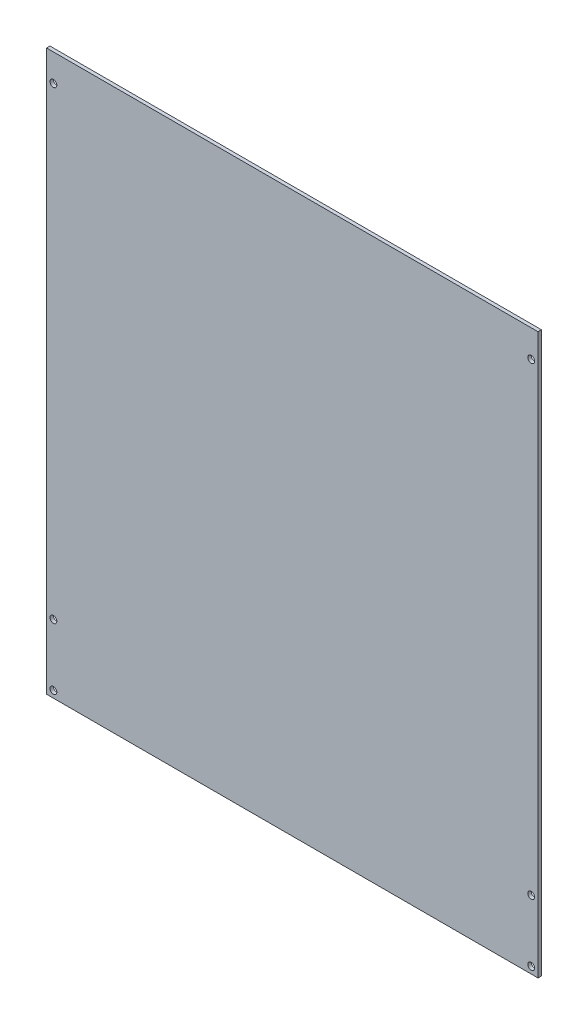
from build123d import *

# Parameters (mm, degrees)
SKETCH1_W           = 457.2
SKETCH1_H           = 520.7
BOSS_EXTRUDE1_DEPTH = 3.175
SKETCH2_R           = 3.175
CUT_EXTRUDE1_DEPTH  = 3.175


with BuildPart() as part:
    # Sketch1 → Boss-Extrude1 (new body)
    with BuildSketch(Plane.XY):
        Rectangle(SKETCH1_W, SKETCH1_H)
    extrude(amount=BOSS_EXTRUDE1_DEPTH)

    # Sketch2 → Cut-Extrude1 (cut)
    with BuildSketch(Plane.XY.offset(3.175)):
        with Locations((-222.25, 234.95)):
            Circle(SKETCH2_R)
        with Locations((222.25, 234.95)):
            Circle(SKETCH2_R)
        with Locations((-222.25, -254)):
            Circle(SKETCH2_R)
        with Locations((222.25, -254)):
            Circle(SKETCH2_R)
        with Locations((-222.25, -196.85)):
            Circle(SKETCH2_R)
        with Locations((222.25, -196.85)):
            Circle(SKETCH2_R)
    extrude(amount=-CUT_EXTRUDE1_DEPTH, mode=Mode.SUBTRACT)


solid = part.part
